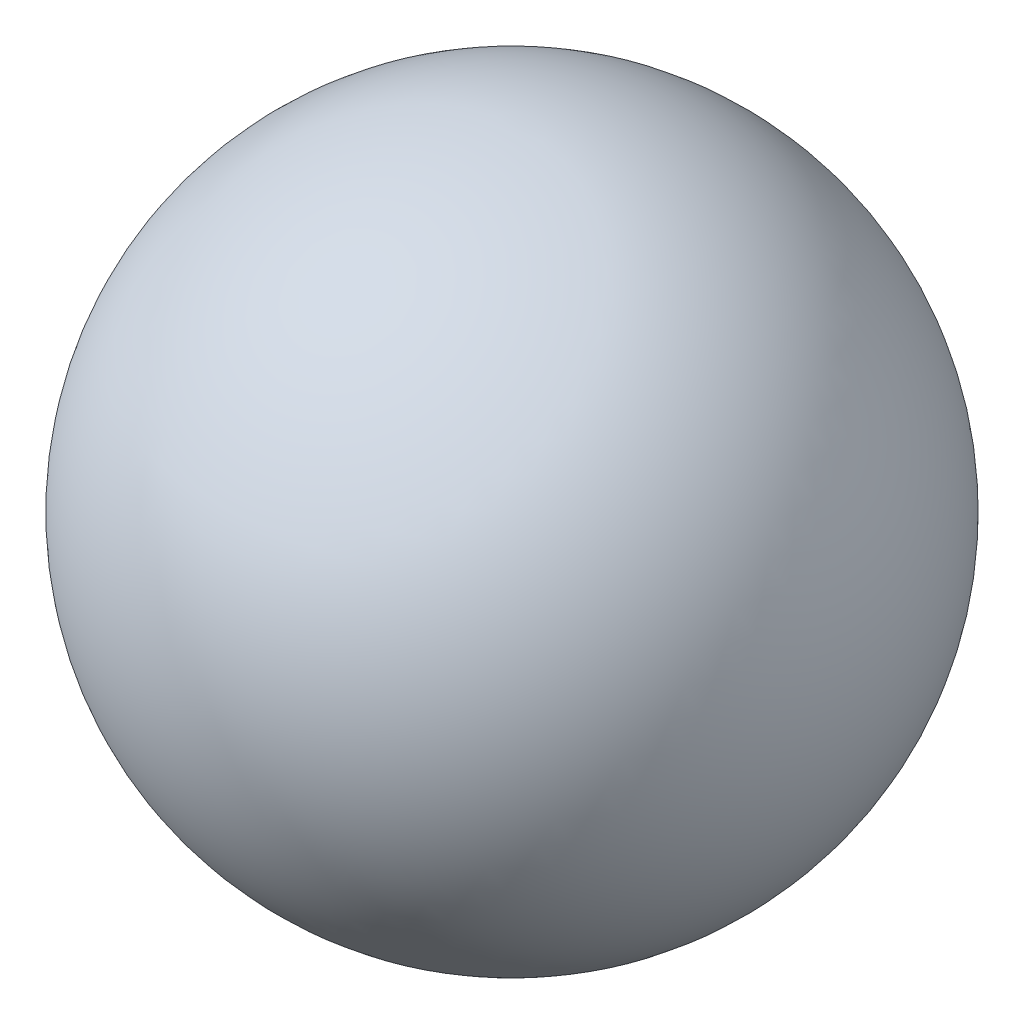
from build123d import *


with BuildPart() as part:
    # Sketch2 → Revolve1 (revolve)
    with BuildSketch(Plane.XY):
        with BuildLine():
            Line((0, 15.875), (0, 15.3924))
            ThreePointArc((0, 15.3924), (15.3924, 0), (0, -15.3924))
            Line((0, -15.3924), (0, -15.875))
            ThreePointArc((0, -15.875), (15.875, 0), (0, 15.875))
        make_face()
    revolve(axis=Axis((0, -158.486323131, 0), (0, 1, 0)))


solid = part.part
